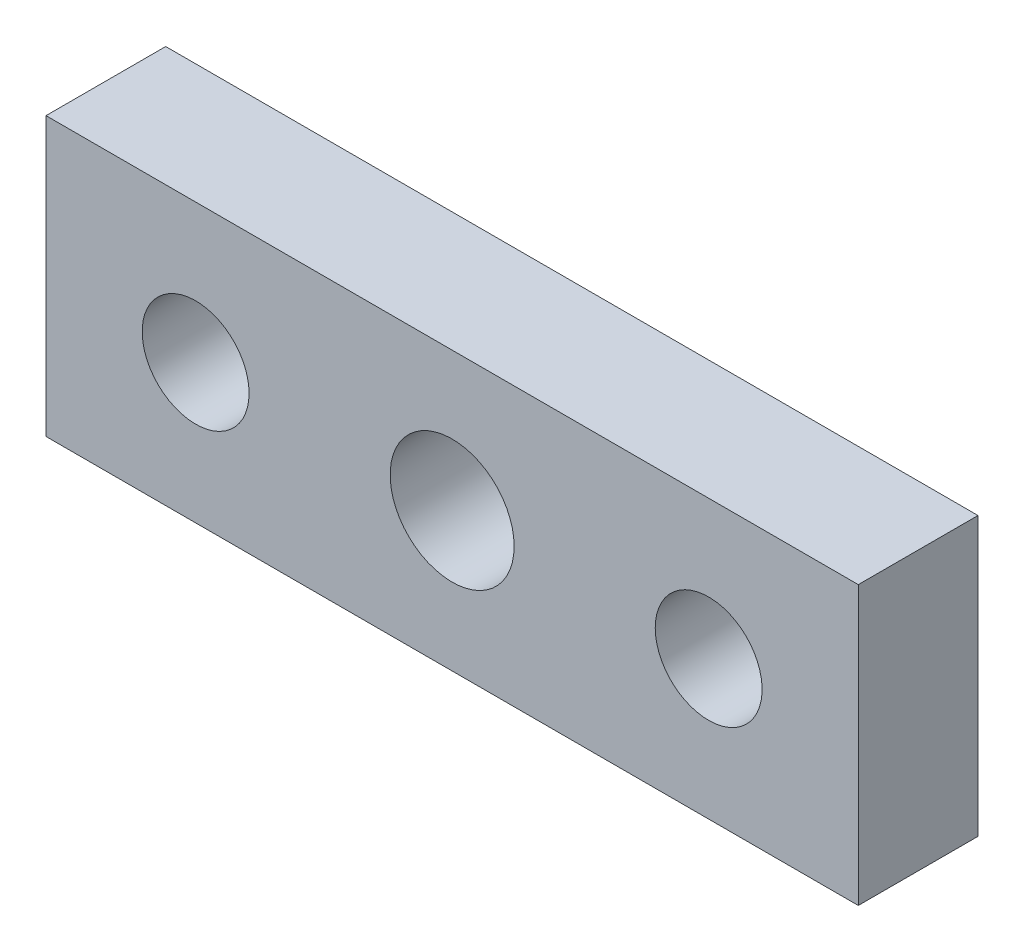
from build123d import *

# Parameters (mm, degrees)
SKETCH1_W           = 38
SKETCH1_H           = 13
SKETCH1_R           = 2.9
SKETCH1_R_2         = 2.5
BOSS_EXTRUDE1_DEPTH = 5.6


with BuildPart() as part:
    # Sketch1 → Boss-Extrude1 (new body)
    with BuildSketch(Plane.XY):
        Rectangle(SKETCH1_W, SKETCH1_H)
        Circle(SKETCH1_R, mode=Mode.SUBTRACT)
        with Locations((-12, 0)):
            Circle(SKETCH1_R_2, mode=Mode.SUBTRACT)
        with Locations((12, 0)):
            Circle(SKETCH1_R_2, mode=Mode.SUBTRACT)
    extrude(amount=BOSS_EXTRUDE1_DEPTH)


solid = part.part
